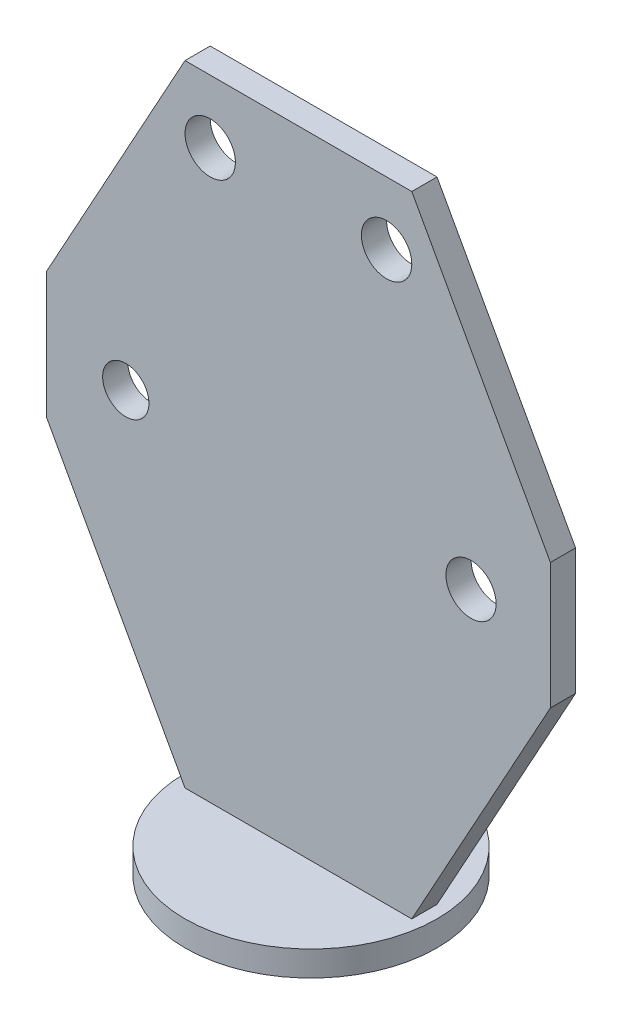
from build123d import *

# Parameters (mm, degrees)
SKETCH_1_R           = 10
EXTRUDE_1_DEPTH      = 2
EXTRUDE_2_DEPTH      = 1
EXTRUDE_2_DEPTH_BACK = 1
SKETCH_3_R           = 2
SKETCH_3_R_2         = 1.992440636
SKETCH_3_R_3         = 1.836667673


with BuildPart() as part:
    # 草图1 → 凸台-拉伸1 (new body)
    with BuildSketch(Plane(origin=(0, 0, 0), x_dir=(1, 0, 0), z_dir=(0, 1, 0))):
        Circle(SKETCH_1_R)
    extrude(amount=EXTRUDE_1_DEPTH)

    # 草图3 → 凸台-拉伸2 (add, two sides: drawn at the far end of the back side and taken through both)
    with BuildSketch(Plane.XY.offset(-EXTRUDE_2_DEPTH_BACK)):
        Polygon((9, 2), (-9, 2), (-20, 22), (-20, 32), (-9, 52), (9, 52), (20, 32), (20, 22), align=None)
        with Locations((-7, 47)):
            Circle(SKETCH_3_R, mode=Mode.SUBTRACT)
        with Locations((7, 47)):
            Circle(SKETCH_3_R, mode=Mode.SUBTRACT)
        with Locations((13.7, 27)):
            Circle(SKETCH_3_R_2, mode=Mode.SUBTRACT)
        with Locations((-13.7, 27)):
            Circle(SKETCH_3_R_3, mode=Mode.SUBTRACT)
    extrude(amount=EXTRUDE_2_DEPTH + EXTRUDE_2_DEPTH_BACK)


solid = part.part
